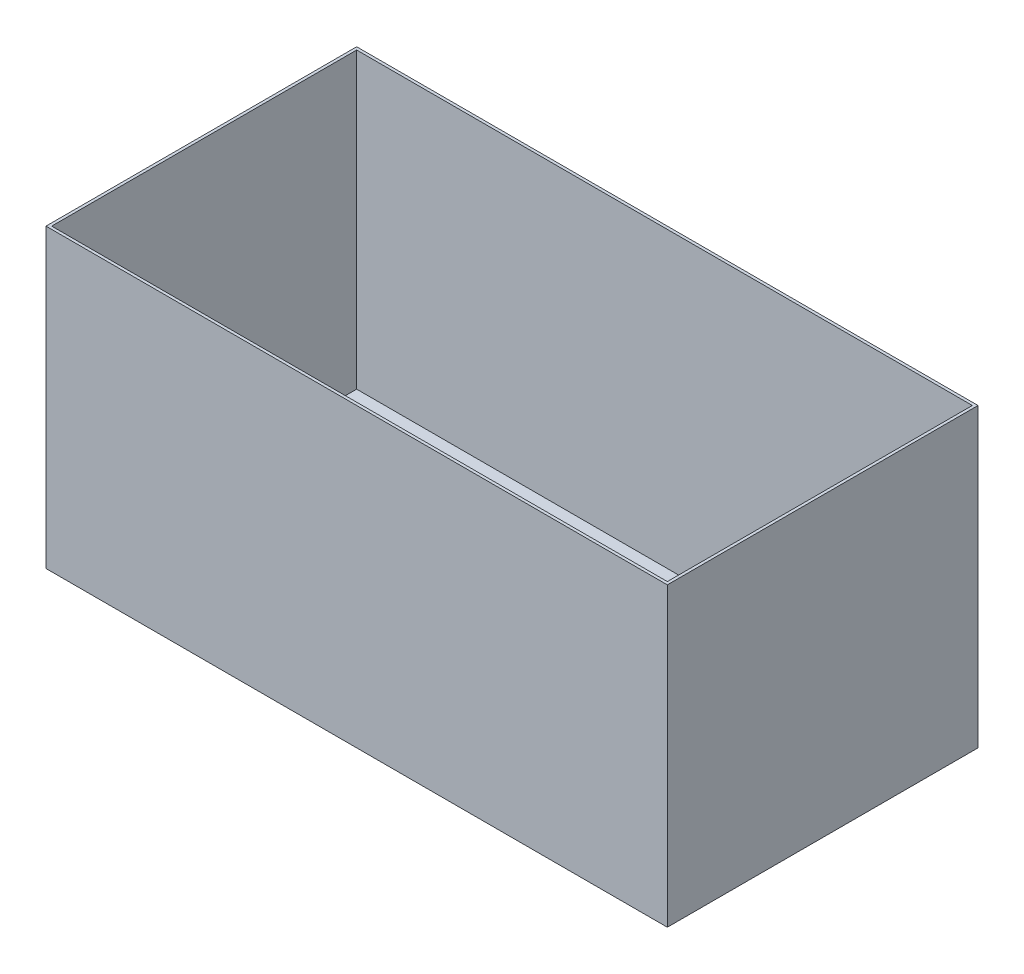
from build123d import *

# Parameters (mm, degrees)
SKETCH1_W          = 2200
SKETCH1_H          = 1100
EXTRUDE1_DEPTH     = 1050
SHELL1_T           = -10
SKETCH2_W          = 600
SKETCH2_H          = 600
CUT_EXTRUDE1_DEPTH = 400


with BuildPart() as part:
    # Sketch1 → Extrude1 (new body)
    with BuildSketch(Plane(origin=(0, 0, 0), x_dir=(1, 0, 0), z_dir=(0, 1, 0))):
        with Locations((-1100, 550)):
            Rectangle(SKETCH1_W, SKETCH1_H)
    extrude(amount=EXTRUDE1_DEPTH)

    # Shell1
    shell1_openings = [part.faces().sort_by_distance(p)[0] for p in [
        (-1100, 1050, -550),
    ]]
    offset(amount=SHELL1_T, openings=shell1_openings, kind=Kind.INTERSECTION)

    # Sketch2 → Cut-Extrude1 (cut)
    with BuildSketch(Plane.XZ):
        with Locations((-400, -550)):
            Rectangle(SKETCH2_W, SKETCH2_H)
    extrude(amount=-CUT_EXTRUDE1_DEPTH, mode=Mode.SUBTRACT)


solid = part.part
